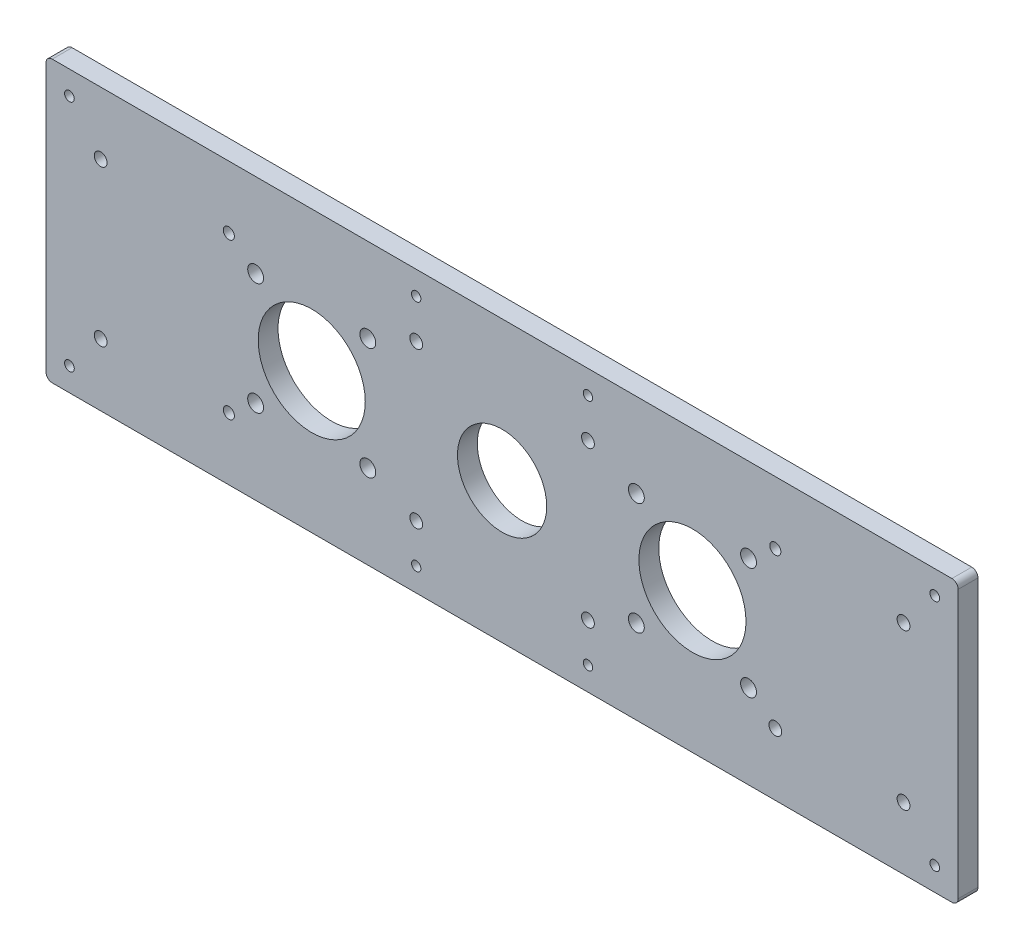
from build123d import *

# Parameters (mm, degrees)
SKETCH1_W           = 292.1
SKETCH1_H           = 89.8
SKETCH1_R           = 14.2875
SKETCH1_R_2         = 2.54
SKETCH1_R_3         = 17.145
BOSS_EXTRUDE1_DEPTH = 6.35
SKETCH2_R           = 2.05
CUT_EXTRUDE1_DEPTH  = 10
SKETCH3_R           = 1.55
SKETCH3_R_2         = 2.05
SKETCH3_R_3         = 1.5
CUT_EXTRUDE2_DEPTH  = 10
FILLET1_R           = 2
SKETCH4_R           = 2.05
SKETCH4_R_2         = 1.778
CUT_EXTRUDE4_DEPTH  = 7.35


with BuildPart() as part:
    # Sketch1 → Boss-Extrude1 (new body)
    with BuildSketch(Plane.XY):
        with Locations((146.05, 44.9)):
            Rectangle(SKETCH1_W, SKETCH1_H)
        with Locations((146.05, 44.9)):
            Circle(SKETCH1_R, mode=Mode.SUBTRACT)
        with Locations((103.051585406, 62.859439014)):
            Circle(SKETCH1_R_2, mode=Mode.SUBTRACT)
        with Locations((103.049439014, 26.938414594)):
            Circle(SKETCH1_R_2, mode=Mode.SUBTRACT)
        with Locations((67.128414594, 26.940560986)):
            Circle(SKETCH1_R_2, mode=Mode.SUBTRACT)
        with Locations((67.130560986, 62.861585406)):
            Circle(SKETCH1_R_2, mode=Mode.SUBTRACT)
        with Locations((85.09, 44.9)):
            Circle(SKETCH1_R_3, mode=Mode.SUBTRACT)
        with Locations((189.050560986, 62.861585406)):
            Circle(SKETCH1_R_2, mode=Mode.SUBTRACT)
        with Locations((224.971585406, 62.859439014)):
            Circle(SKETCH1_R_2, mode=Mode.SUBTRACT)
        with Locations((224.969439014, 26.938414594)):
            Circle(SKETCH1_R_2, mode=Mode.SUBTRACT)
        with Locations((189.048414594, 26.940560986)):
            Circle(SKETCH1_R_2, mode=Mode.SUBTRACT)
        with Locations((207.01, 44.9)):
            Circle(SKETCH1_R_3, mode=Mode.SUBTRACT)
    extrude(amount=BOSS_EXTRUDE1_DEPTH)

    # Sketch2 → Cut-Extrude1 (cut)
    with BuildSketch(Plane.XY.offset(6.35)):
        with Locations((118.55, 20)):
            Circle(SKETCH2_R)
        with Locations((118.55, 69.8)):
            Circle(SKETCH2_R)
        with Locations((173.55, 20)):
            Circle(SKETCH2_R)
        with Locations((173.55, 69.8)):
            Circle(SKETCH2_R)
    extrude(amount=-CUT_EXTRUDE1_DEPTH, mode=Mode.SUBTRACT)

    # Sketch3 → Cut-Extrude2 (cut)
    with BuildSketch(Plane.XY.offset(6.35)):
        with Locations((284.6, 7.5)):
            Circle(SKETCH3_R)
        with Locations((7.5, 7.5)):
            Circle(SKETCH3_R)
        with Locations((7.5, 82.3)):
            Circle(SKETCH3_R)
        with Locations((284.6, 82.3)):
            Circle(SKETCH3_R)
        with Locations((274.6, 20)):
            Circle(SKETCH3_R_2)
        with Locations((17.5, 20)):
            Circle(SKETCH3_R_2)
        with Locations((17.5, 69.8)):
            Circle(SKETCH3_R_2)
        with Locations((274.6, 69.8)):
            Circle(SKETCH3_R_2)
        with Locations((173.55, 7.5)):
            Circle(SKETCH3_R_3)
        with Locations((173.55, 82.3)):
            Circle(SKETCH3_R_3)
        with Locations((118.55, 82.3)):
            Circle(SKETCH3_R_3)
        with Locations((118.55, 7.5)):
            Circle(SKETCH3_R_3)
    extrude(amount=-CUT_EXTRUDE2_DEPTH, mode=Mode.SUBTRACT)

    # Fillet1
    fillet1_edges = [part.edges().sort_by_distance(p)[0] for p in [
        (0, 89.8, 3.175),
        (292.1, 89.8, 3.175),
        (292.1, 0, 3.175),
        (0, 0, 3.175),
    ]]
    fillet(fillet1_edges, radius=FILLET1_R)

    # Sketch4 → Cut-Extrude4 (cut, through all)
    with BuildSketch(Plane.XY.offset(6.35)):
        with Locations((233.55, 20)):
            Circle(SKETCH4_R)
        with Locations((233.55, 69.8)):
            Circle(SKETCH4_R_2)
        with Locations((58.55, 69.8)):
            Circle(SKETCH4_R_2)
        with Locations((58.55, 20)):
            Circle(SKETCH4_R_2)
    extrude(amount=-CUT_EXTRUDE4_DEPTH, mode=Mode.SUBTRACT)


solid = part.part
